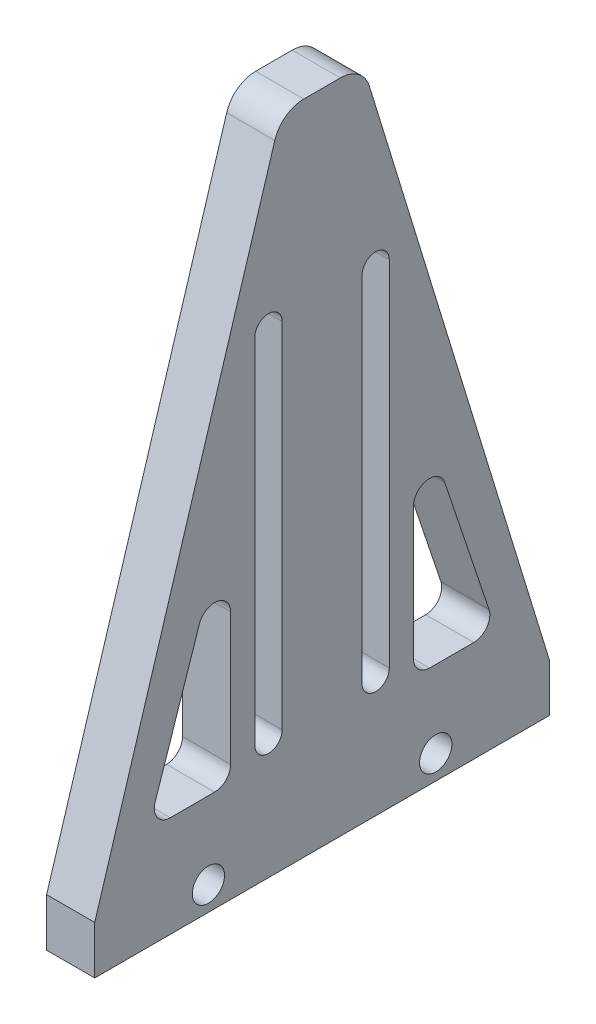
from build123d import *

# Parameters (mm, degrees)
BOSS_EXTRUDE1_DEPTH  = 2.3815
M3_CLEARANCE_HOLE1_D = 3.2


with BuildPart() as part:
    # Sketch1 → Boss-Extrude1 (new body, symmetric)
    with BuildSketch(Plane(origin=(0, 0, 0), x_dir=(0, 0, -1), z_dir=(1, 0, 0))):
        with BuildLine():
            Line((-22.5, 0), (22.5, 0))
            Line((22.5, 0), (22.5, 4.763))
            Line((22.5, 4.763), (4.677891876, 62.879556228))
            ThreePointArc((4.677891876, 62.879556228), (3.593167148, 64.41232965), (1.809725067, 65))
            Line((1.809725067, 65), (-1.809725067, 65))
            ThreePointArc((-1.809725067, 65), (-3.593167148, 64.41232965), (-4.677891876, 62.879556228))
            Line((-4.677891876, 62.879556228), (-22.5, 4.763))
            Line((-22.5, 4.763), (-22.5, 0))
        make_face()
        with BuildLine():
            Line((-3.955008566, 47), (-3.955008566, 12))
            ThreePointArc((-3.955008566, 12), (-5.305008566, 10.65), (-6.655008566, 12))
            Line((-6.655008566, 12), (-6.655008566, 47))
            ThreePointArc((-6.655008566, 47), (-5.305008566, 48.35), (-3.955008566, 47))
        make_face(mode=Mode.SUBTRACT)
        with BuildLine():
            Line((6.655008566, 47), (6.655008566, 12))
            ThreePointArc((6.655008566, 12), (5.305008566, 10.65), (3.955008566, 12))
            Line((3.955008566, 12), (3.955008566, 47))
            ThreePointArc((3.955008566, 47), (5.305008566, 48.35), (6.655008566, 47))
        make_face(mode=Mode.SUBTRACT)
        with BuildLine():
            Line((12.138351874, 25.164576479), (16.522078624, 12.092233924))
            ThreePointArc((16.522078624, 12.092233924), (16.305639712, 10.660437126), (15.016954073, 10))
            Line((15.016954073, 10), (10.633227322, 10))
            ThreePointArc((10.633227322, 10), (9.510695307, 10.464967985), (9.045727322, 11.5875))
            Line((9.045727322, 11.5875), (9.045727322, 24.659842555))
            ThreePointArc((9.045727322, 24.659842555), (10.377521412, 26.226613354), (12.138351874, 25.164576479))
        make_face(mode=Mode.SUBTRACT)
        with BuildLine():
            Line((-9.045727322, 24.659842555), (-9.045727322, 11.5875))
            ThreePointArc((-9.045727322, 11.5875), (-9.510695307, 10.464967985), (-10.633227322, 10))
            Line((-10.633227322, 10), (-15.016954073, 10))
            ThreePointArc((-15.016954073, 10), (-16.305639712, 10.660437126), (-16.522078624, 12.092233924))
            Line((-16.522078624, 12.092233924), (-12.138351874, 25.164576479))
            ThreePointArc((-12.138351874, 25.164576479), (-10.377521412, 26.226613354), (-9.045727322, 24.659842555))
        make_face(mode=Mode.SUBTRACT)
    extrude(amount=BOSS_EXTRUDE1_DEPTH, both=True)

    # M3 Clearance Hole1 (through all)
    with Locations(Plane(origin=(2.3815, 0, 0), x_dir=(0, 0, -1), z_dir=(1, 0, 0))):
        with Locations((-11.25, 2.3815), (11.25, 2.3815)):
            Hole(M3_CLEARANCE_HOLE1_D / 2)


solid = part.part
